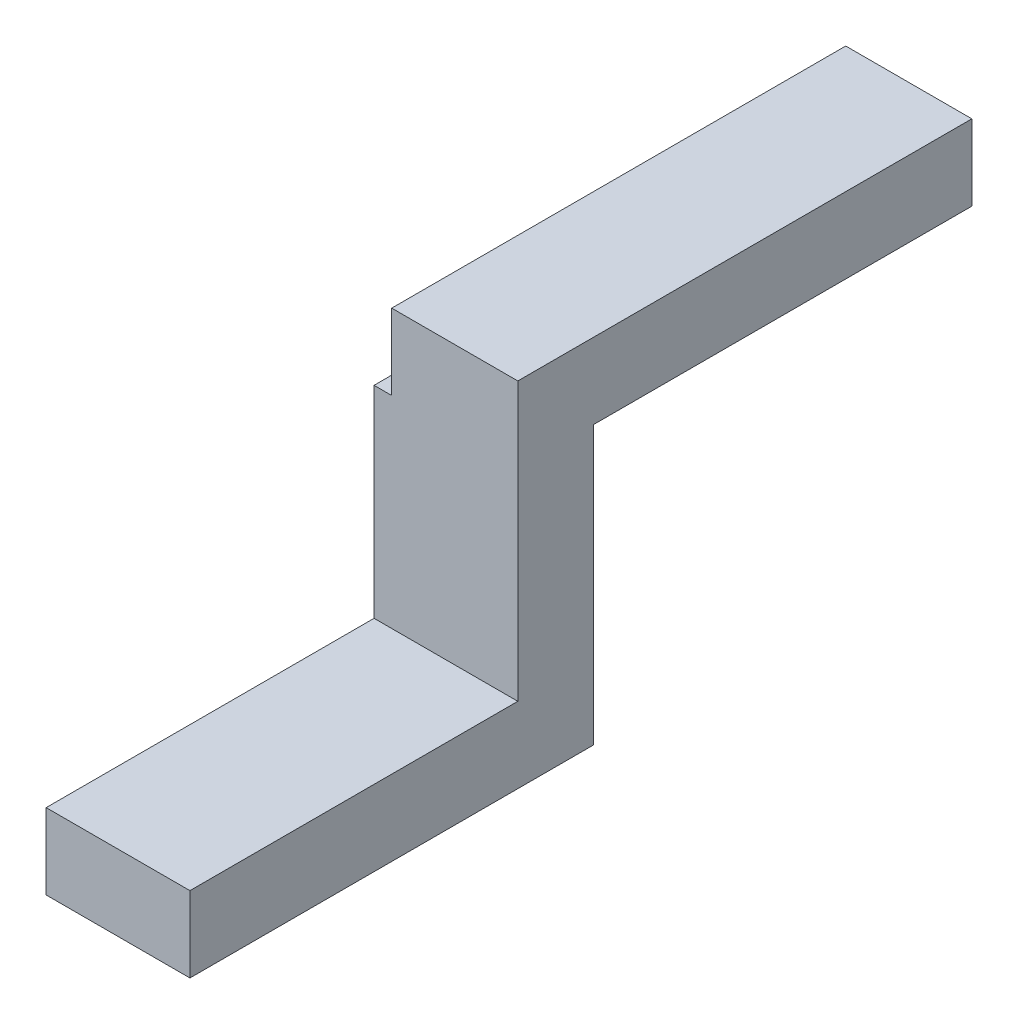
from build123d import *

# Parameters (mm, degrees)
BOSS_EXTRUDE1_DEPTH = 5.7
SKETCH2_W           = 0.7
SKETCH2_H           = 3
CUT_EXTRUDE1_DEPTH  = 19


with BuildPart() as part:
    # Sketch1 → Boss-Extrude1 (new body)
    with BuildSketch(Plane(origin=(0, 0, 0), x_dir=(0, 0, -1), z_dir=(1, 0, 0))):
        Polygon((-16, 3), (-3, 3), (-3, 14), (15, 14), (15, 11), (0, 11), (0, 0), (-16, 0), align=None)
    extrude(amount=BOSS_EXTRUDE1_DEPTH)

    # Sketch2 → Cut-Extrude1 (cut, through all)
    with BuildSketch(Plane.XY.offset(3)):
        with Locations((0.35, 12.5)):
            Rectangle(SKETCH2_W, SKETCH2_H)
    extrude(amount=-CUT_EXTRUDE1_DEPTH, mode=Mode.SUBTRACT)


solid = part.part
